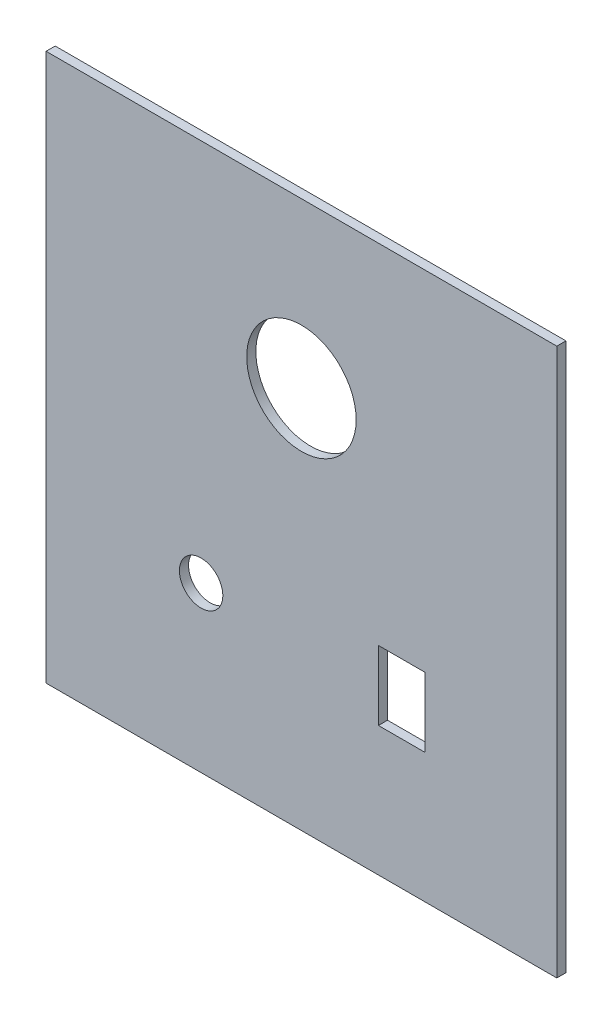
from build123d import *

# Parameters (mm, degrees)
CROQUIS1_W              = 140
CROQUIS1_H              = 150
CROQUIS1_R              = 5.95
CROQUIS1_R_2            = 15
CROQUIS1_W_2            = 12.8
CROQUIS1_H_2            = 19
SALIENTE_EXTRUIR1_DEPTH = 2.5


with BuildPart() as part:
    # Croquis1 → Saliente-Extruir1 (new body)
    with BuildSketch(Plane.XY):
        Rectangle(CROQUIS1_W, CROQUIS1_H)
        with Locations((-27.5, -30)):
            Circle(CROQUIS1_R, mode=Mode.SUBTRACT)
        with Locations((0, 30)):
            Circle(CROQUIS1_R_2, mode=Mode.SUBTRACT)
        with Locations((27.5, -30)):
            Rectangle(CROQUIS1_W_2, CROQUIS1_H_2, mode=Mode.SUBTRACT)
    extrude(amount=SALIENTE_EXTRUIR1_DEPTH)


solid = part.part
